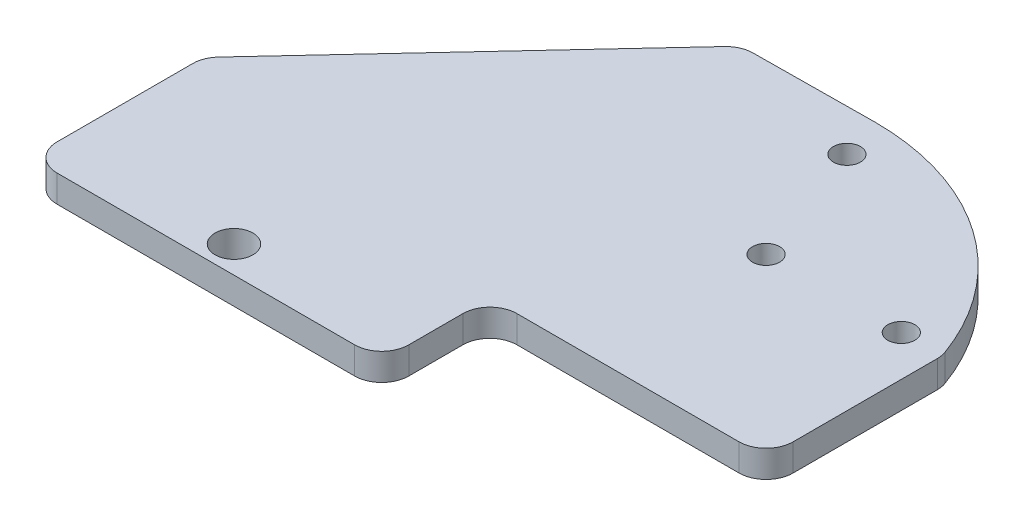
from build123d import *

# Parameters (mm, degrees)
BOSS_EXTRUDE1_DEPTH     = 10
SKETCH2_R               = 5
CUT_EXTRUDE4_DEPTH      = 11
CUT_EXTRUDE4_DEPTH_BACK = 1
SKETCH3_R               = 7
CUT_EXTRUDE5_DEPTH      = 11


with BuildPart() as part:
    # Sketch1 → Boss-Extrude1 (new body)
    with BuildSketch(Plane(origin=(0, 0, 0), x_dir=(1, 0, 0), z_dir=(0, 1, 0))):
        with BuildLine():
            Line((5, 0), (87.1, 0))
            ThreePointArc((87.1, 0), (94.171067812, 2.928932188), (97.1, 10))
            Line((97.1, 10), (97.1, 63.297208828))
            ThreePointArc((97.1, 63.297208828), (96.949532816, 65.025416948), (96.502659338, 66.701617347))
            ThreePointArc((96.502659338, 66.701617347), (62.853663281, 110.72240479), (10.046495568, 127.5))
            Line((10.046495568, 127.5), (-34.953504432, 127.079547292))
            ThreePointArc((-34.953504432, 127.079547292), (-38.861917641, 126.217874558), (-42.119413536, 123.892601626))
            Line((-42.119413536, 123.892601626), (-132.321113421, 26.947294417))
            ThreePointArc((-132.321113421, 26.947294417), (-134.306211211, 23.795285131), (-135, 20.135444575))
            Line((-135, 20.135444575), (-135, -30))
            ThreePointArc((-135, -30), (-132.071067812, -37.071067812), (-125, -40))
            Line((-125, -40), (-15, -40))
            ThreePointArc((-15, -40), (-7.928932188, -37.071067812), (-5, -30))
            Line((-5, -30), (-5, -10))
            ThreePointArc((-5, -10), (-2.071067812, -2.928932188), (5, 0))
        make_face()
    extrude(amount=BOSS_EXTRUDE1_DEPTH)

    # Sketch2 → Cut-Extrude4 (cut, two sides)
    with BuildSketch(Plane(origin=(0, 0, 0), x_dir=(1, 0, 0), z_dir=(0, 1, 0))) as cut_extrude4_sk:
        with Locations((14.998992834, 111.984631039)):
            Circle(SKETCH2_R)
        with Locations((82.1, 65)):
            Circle(SKETCH2_R)
        with Locations((32.1, 65)):
            Circle(SKETCH2_R)
    extrude(amount=CUT_EXTRUDE4_DEPTH, mode=Mode.SUBTRACT)
    extrude(cut_extrude4_sk.sketch, amount=-CUT_EXTRUDE4_DEPTH_BACK, mode=Mode.SUBTRACT)

    # Sketch3 → Cut-Extrude5 (cut, through all)
    with BuildSketch(Plane.XZ):
        with Locations((-69.615384615, 30)):
            Circle(SKETCH3_R)
    extrude(amount=-CUT_EXTRUDE5_DEPTH, mode=Mode.SUBTRACT)


solid = part.part
